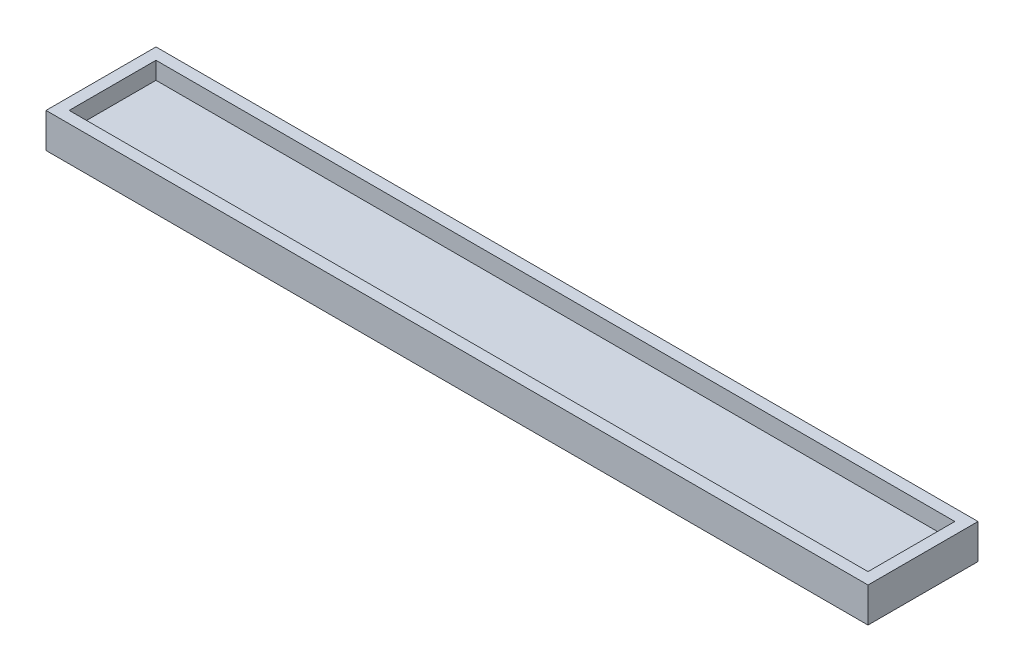
from build123d import *

# Parameters (mm, degrees)
SKETCH1_W           = 138
SKETCH1_H           = 15
BOSS_EXTRUDE1_DEPTH = 3
SKETCH2_W           = 142
SKETCH2_H           = 19
SKETCH2_W_2         = 138
SKETCH2_H_2         = 15
BOSS_EXTRUDE2_DEPTH = 6


with BuildPart() as part:
    # Sketch1 → Boss-Extrude1 (new body)
    with BuildSketch(Plane(origin=(0, 0, 0), x_dir=(1, 0, 0), z_dir=(0, 1, 0))):
        with Locations((69, 7.5)):
            Rectangle(SKETCH1_W, SKETCH1_H)
    extrude(amount=BOSS_EXTRUDE1_DEPTH)

    # Sketch2 → Boss-Extrude2 (add)
    with BuildSketch(Plane.XZ):
        with Locations((69, -7.5)):
            Rectangle(SKETCH2_W, SKETCH2_H)
        with Locations((69, -7.5)):
            Rectangle(SKETCH2_W_2, SKETCH2_H_2, mode=Mode.SUBTRACT)
    extrude(amount=-BOSS_EXTRUDE2_DEPTH)


solid = part.part
